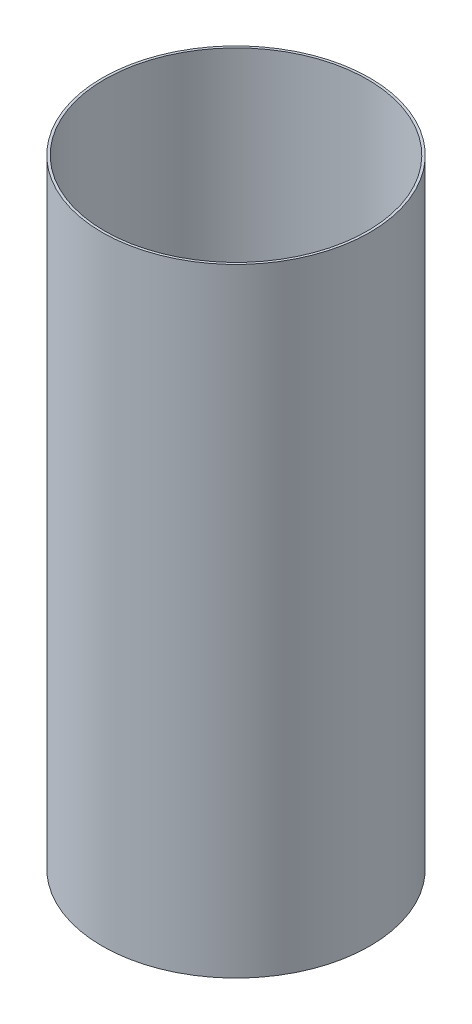
from build123d import *

# Parameters (mm, degrees)
SKETCH1_R           = 55
SKETCH1_R_2         = 54
BOSS_EXTRUDE1_DEPTH = 254


with BuildPart() as part:
    # Sketch1 → Boss-Extrude1 (new body)
    with BuildSketch(Plane(origin=(0, 0, 0), x_dir=(1, 0, 0), z_dir=(0, 1, 0))):
        Circle(SKETCH1_R)
        Circle(SKETCH1_R_2, mode=Mode.SUBTRACT)
    extrude(amount=BOSS_EXTRUDE1_DEPTH)


solid = part.part
